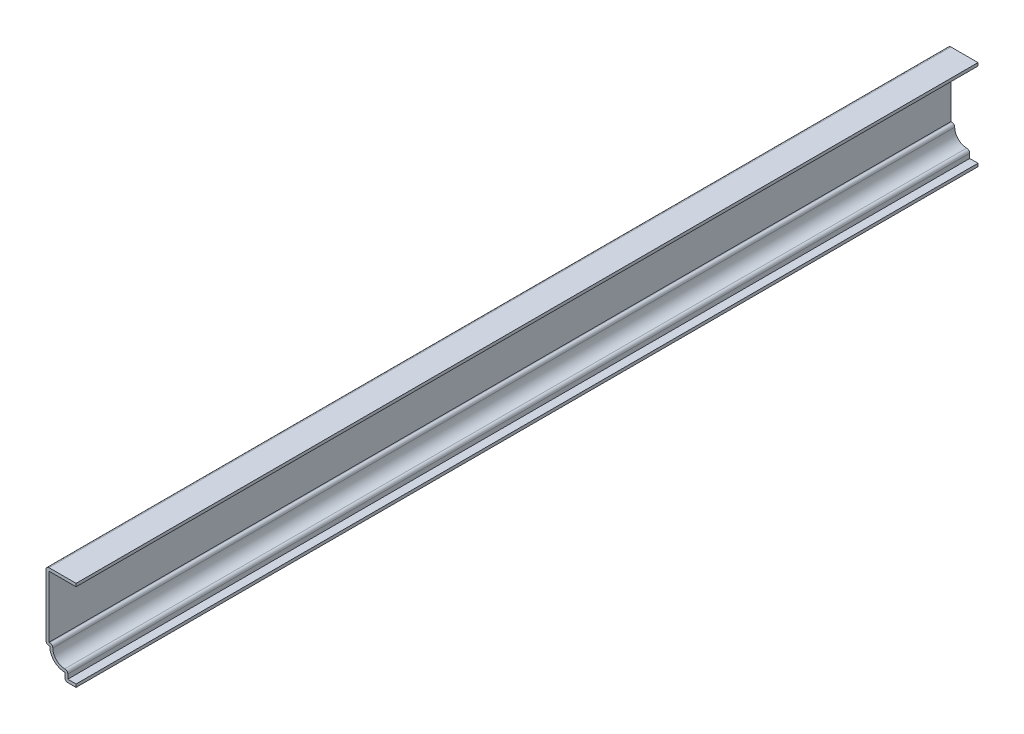
from build123d import *

# Parameters (mm, degrees)
EXTRUDE_THIN1_DEPTH = 381
FILLET1_R           = 1.27


with BuildPart() as part:
    # Sketch1 → Extrude-Thin1 (new body)
    with BuildSketch(Plane.XY):
        with BuildLine():
            Line((0, 0), (-4.7625, 0))
            Line((-4.7625, 0), (-4.7625, 3.175))
            ThreePointArc((-4.7625, 3.175), (-9.252628061, 5.034871939), (-11.1125, 9.525))
            Line((-11.1125, 9.525), (-12.7, 9.525))
            Line((-12.7, 9.525), (-12.7, 38.1))
            Line((-12.7, 38.1), (0, 38.1))
            Line((0, 38.1), (0, 36.83))
            Line((0, 36.83), (-11.43, 36.83))
            Line((-11.43, 36.83), (-11.43, 10.795))
            Line((-11.43, 10.795), (-9.68118885, 10.795))
            ThreePointArc((-9.68118885, 10.795), (-8.354602448, 5.932897552), (-3.4925, 4.60631115))
            Line((-3.4925, 4.60631115), (-3.4925, 1.27))
            Line((-3.4925, 1.27), (0, 1.27))
            Line((0, 1.27), (0, 0))
        make_face()
    extrude(amount=-EXTRUDE_THIN1_DEPTH)

    # Fillet1
    fillet1_edges = [part.edges().sort_by_distance(p)[0] for p in [
        (-9.68118885, 10.795, -190.5),
        (-3.4925, 4.60631115, -190.5),
        (-4.7625, 0, -190.5),
        (-12.7, 9.525, -190.5),
        (-12.7, 38.1, -190.5),
    ]]
    fillet(fillet1_edges, radius=FILLET1_R)


solid = part.part
